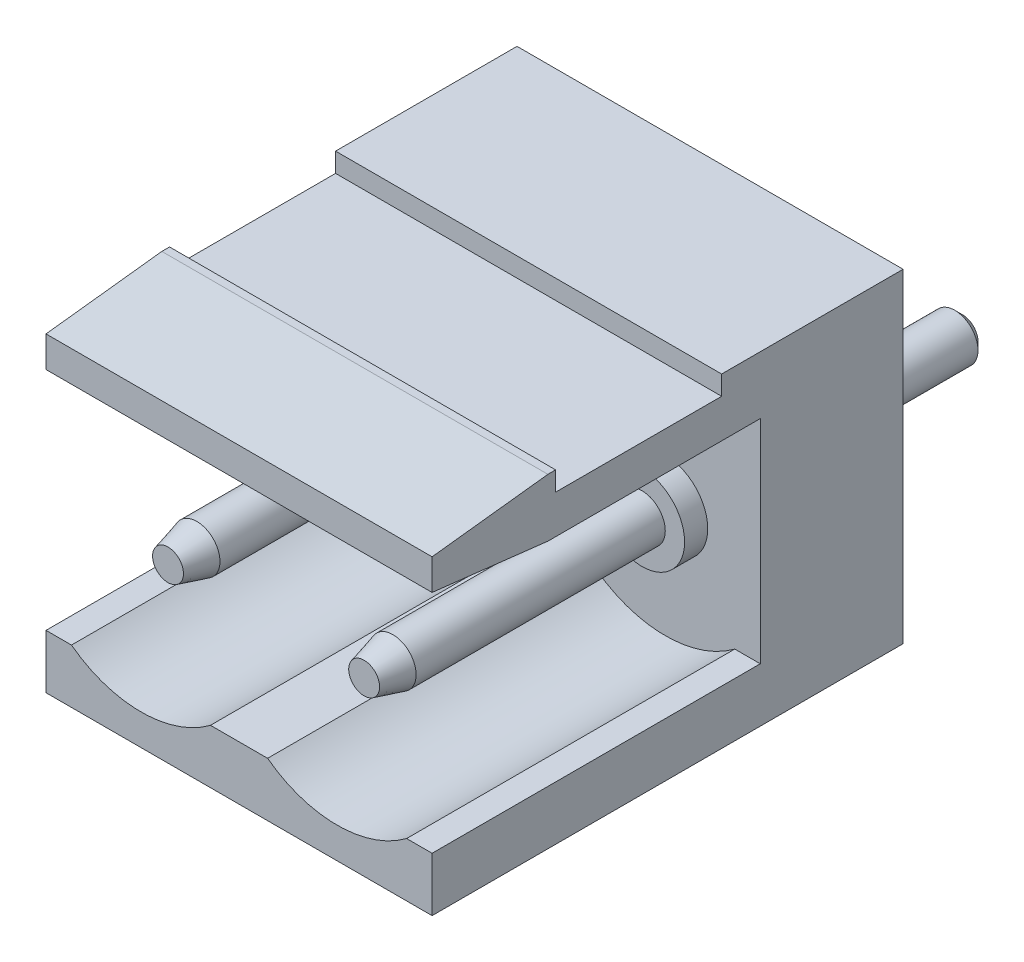
from build123d import *

# Parameters (mm, degrees)
ESQUISSE1_W             = 10
ESQUISSE1_H             = 8.4
BOSS_EXTRU_1_DEPTH      = 12.2
ENL_V_MAT_EXTRU_1_DEPTH = 8.5
ESQUISSE3_W             = 4.3
ESQUISSE3_H             = 0.5
ENL_V_MAT_EXTRU_2_DEPTH = 11
ESQUISSE4_R             = 0.6
BOSS_EXTRU_2_DEPTH      = 4
BOSS_EXTRU_2_DEPTH_BACK = 11.5
CHANFREIN1_SIZE         = 0.2
CHANFREIN1_SIZE2        = 0.746410162
CHANFREIN1_PART_2_SIZE  = 0.2
CHANFREIN1_PART_2_SIZE2 = 0.746410162
CHANFREIN2_SIZE         = 0.2
ESQUISSE5_R             = 1.1
BOSS_EXTRU_3_DEPTH      = 0.6


with BuildPart() as part:
    # Esquisse1 → Boss.-Extru.1 (new body)
    with BuildSketch(Plane.XY):
        with Locations((5, 4.2)):
            Rectangle(ESQUISSE1_W, ESQUISSE1_H)
    extrude(amount=BOSS_EXTRU_1_DEPTH)

    # Esquisse2 → Enlèv. mat.-Extru.1 (cut)
    with BuildSketch(Plane.XY.offset(12.2)):
        with BuildLine():
            Line((0, 1.4), (0, 6.9))
            Line((0, 6.9), (10, 6.9))
            Line((10, 6.9), (10, 1.4))
            Line((10, 1.4), (9.34, 1.4))
            ThreePointArc((9.34, 1.4), (7.54, 0.8), (5.74, 1.4))
            Line((5.74, 1.4), (4.26, 1.4))
            ThreePointArc((4.26, 1.4), (2.46, 0.8), (0.66, 1.4))
            Line((0.66, 1.4), (0, 1.4))
        make_face()
    extrude(amount=-ENL_V_MAT_EXTRU_1_DEPTH, mode=Mode.SUBTRACT)

    # Esquisse3 → Enlèv. mat.-Extru.2 (cut, through all)
    with BuildSketch(Plane.ZY):
        with Locations((6.85, 8.15)):
            Rectangle(ESQUISSE3_W, ESQUISSE3_H)
        Polygon((12.2, 8.4), (9.2, 8.4), (12.2, 8.05), align=None)
        Polygon((12.2, 7.25), (12.2, 6.9), (9.2, 6.9), align=None)
    extrude(amount=-ENL_V_MAT_EXTRU_2_DEPTH, mode=Mode.SUBTRACT)

    # Esquisse4 → Boss.-Extru.2 (add, two sides)
    with BuildSketch(Plane(origin=(0, 0, 0), x_dir=(-1, 0, 0), z_dir=(0, 0, -1))) as boss_extru_2_sk:
        with Locations((-7.54, 3.75)):
            Circle(ESQUISSE4_R)
        with Locations((-2.46, 3.75)):
            Circle(ESQUISSE4_R)
    extrude(amount=BOSS_EXTRU_2_DEPTH)
    extrude(boss_extru_2_sk.sketch, amount=-BOSS_EXTRU_2_DEPTH_BACK)

    # Chanfrein1
    chanfrein1_edges = [part.edges().sort_by_distance(p)[0] for p in [
        (8.14, 3.75, 11.5),
    ]]
    chanfrein1_side = [part.faces().sort_by_distance(p)[0] for p in [
        (7.54, 3.75, 11.5),
    ]]
    chamfer(chanfrein1_edges, length=CHANFREIN1_SIZE, length2=CHANFREIN1_SIZE2, reference=chanfrein1_side[0])

    # Chanfrein1 part 2
    chanfrein1_part_2_edges = [part.edges().sort_by_distance(p)[0] for p in [
        (3.06, 3.75, 11.5),
    ]]
    chanfrein1_part_2_side = [part.faces().sort_by_distance(p)[0] for p in [
        (2.46, 3.75, 11.5),
    ]]
    chamfer(chanfrein1_part_2_edges, length=CHANFREIN1_PART_2_SIZE, length2=CHANFREIN1_PART_2_SIZE2, reference=chanfrein1_part_2_side[0])

    # Chanfrein2
    chanfrein2_edges = [part.edges().sort_by_distance(p)[0] for p in [
        (8.14, 3.75, -4),
        (3.06, 3.75, -4),
    ]]
    chamfer(chanfrein2_edges, length=CHANFREIN2_SIZE)

    # Esquisse5 → Boss.-Extru.3 (add)
    with BuildSketch(Plane.XY.offset(3.7)):
        with Locations((2.46, 3.75)):
            Circle(ESQUISSE5_R)
        with Locations((7.54, 3.75)):
            Circle(ESQUISSE5_R)
    extrude(amount=BOSS_EXTRU_3_DEPTH)


solid = part.part
